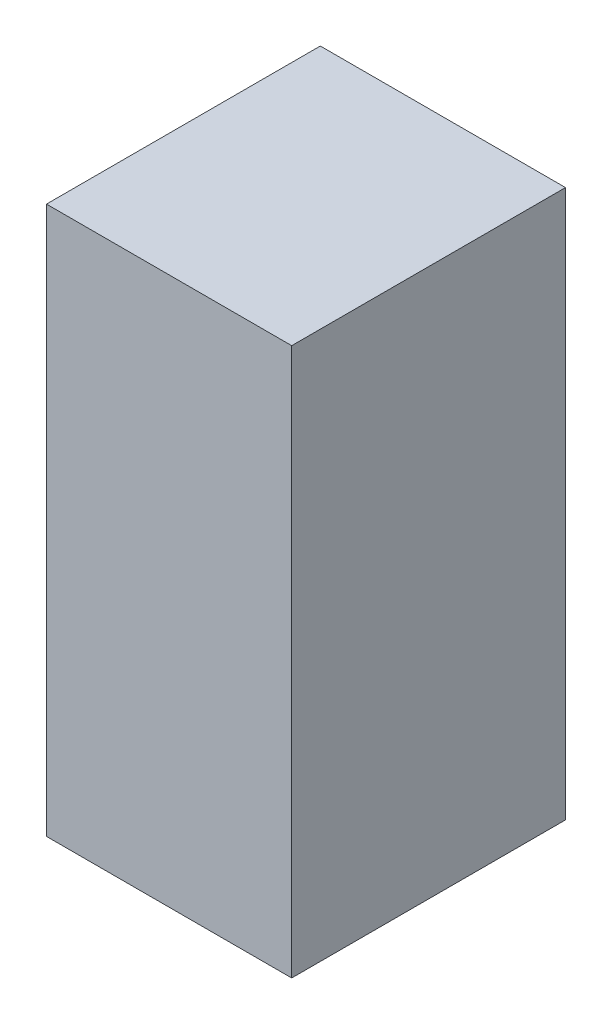
from build123d import *

# Parameters (mm, degrees)
SKETCH1_W      = 60
SKETCH1_H      = 134
EXTRUDE1_DEPTH = 67


with BuildPart() as part:
    # Sketch1 → Extrude1 (new body)
    with BuildSketch(Plane.XY):
        with Locations((0, 67)):
            Rectangle(SKETCH1_W, SKETCH1_H)
    extrude(amount=EXTRUDE1_DEPTH)


solid = part.part
